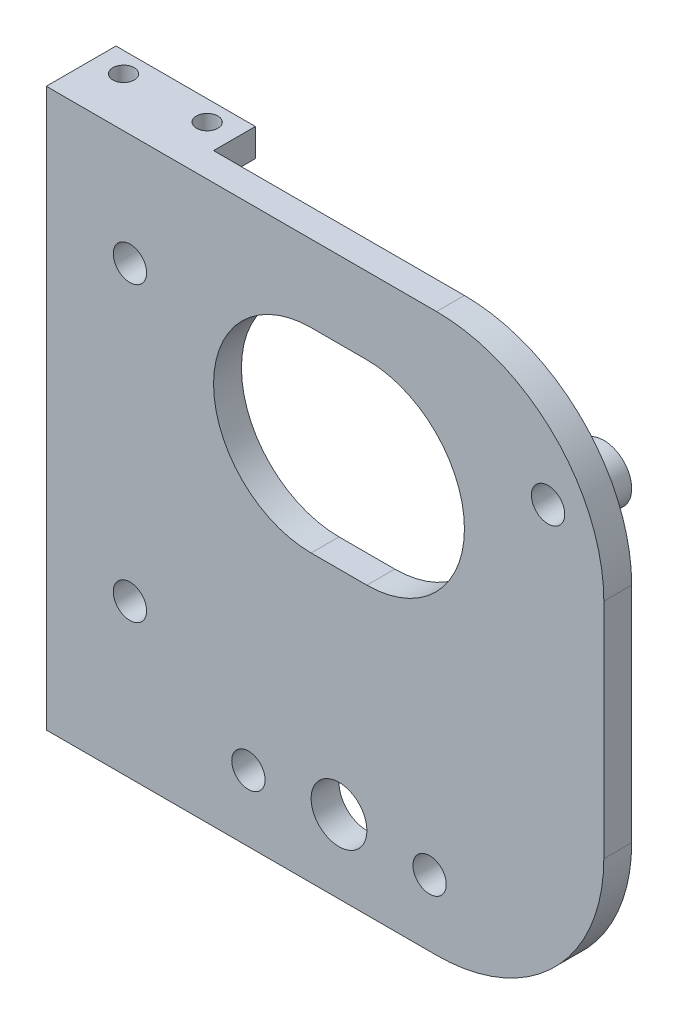
from build123d import *

# Parameters (mm, degrees)
SKETCH1_W                 = 63.5
SKETCH1_H                 = 63.5
BOSS_EXTRUDE1_DEPTH       = 3.175
BOSS_EXTRUDE2_DEPTH       = 4.7625
F_2_CLEARANCE_HOLE2_D     = 2.4384
F_2_CLEARANCE_HOLE2_DEPTH = 3.155006513
FILLET1_R                 = 19.05
SKETCH7_W                 = 15.875
SKETCH7_H                 = 3.175
BOSS_EXTRUDE3_DEPTH       = 4.7625
F_2_CLEARANCE_HOLE3_D     = 2.4384
F_2_CLEARANCE_HOLE3_DEPTH = 3.175
BOSS_EXTRUDE4_START       = -3.175
SKETCH10_R                = 3.175
BOSS_EXTRUDE4_DEPTH       = 3.175
F_6_CLEARANCE_HOLE1_D     = 3.7973
SKETCH13_R                = 3.175
CUT_EXTRUDE1_DEPTH        = 3.175


with BuildPart() as part:
    # Sketch1 → Boss-Extrude1 (new body)
    with BuildSketch(Plane.XY):
        Rectangle(SKETCH1_W, SKETCH1_H)
    extrude(amount=BOSS_EXTRUDE1_DEPTH)

    # Sketch2 → Boss-Extrude2 (add)
    with BuildSketch(Plane(origin=(0, 0, 0), x_dir=(-1, 0, 0), z_dir=(0, 0, -1))):
        Polygon((15.875, -31.75), (25.4, -31.75), (31.75, -31.75), (31.75, -28.594993487), (25.755751185, -28.594993487), (15.875, -28.594993487), align=None)
    extrude(amount=BOSS_EXTRUDE2_DEPTH)

    # #2 Clearance Hole2
    with Locations(Plane(origin=(0, -28.594993487, 0), x_dir=(1, 0, 0), z_dir=(0, 1, 0))):
        with Locations((-28.575, 2.447629477), (-19.05, 2.447629477)):
            Hole(F_2_CLEARANCE_HOLE2_D / 2, depth=F_2_CLEARANCE_HOLE2_DEPTH)

    # Fillet1
    fillet1_edges = [part.edges().sort_by_distance(p)[0] for p in [
        (31.75, -31.75, 1.5875),
        (31.75, 31.75, 1.5875),
    ]]
    fillet(fillet1_edges, radius=FILLET1_R)

    # Sketch7 → Boss-Extrude3 (add)
    with BuildSketch(Plane(origin=(0, 0, 0), x_dir=(-1, 0, 0), z_dir=(0, 0, -1))):
        with Locations((23.8125, 30.1625)):
            Rectangle(SKETCH7_W, SKETCH7_H)
    extrude(amount=BOSS_EXTRUDE3_DEPTH)

    # #2 Clearance Hole3
    with Locations(Plane(origin=(0, 31.75, 0), x_dir=(1, 0, 0), z_dir=(0, 1, 0))):
        with Locations((-28.575, 2.447629477), (-19.05, 2.447629477)):
            Hole(F_2_CLEARANCE_HOLE3_D / 2, depth=F_2_CLEARANCE_HOLE3_DEPTH)

    # Sketch10 → Boss-Extrude4 (add)
    with BuildSketch(Plane.XY.offset(3.175).offset(BOSS_EXTRUDE4_START)):
        with Locations((25.4, 19.05)):
            Circle(SKETCH10_R)
        with Locations((-22.225, 19.05)):
            Circle(SKETCH10_R)
        with Locations((-22.225, -14.2875)):
            Circle(SKETCH10_R)
        with Locations((-8.73125, -24.209375)):
            Circle(SKETCH10_R)
        with Locations((11.90625, -24.209375)):
            Circle(SKETCH10_R)
    extrude(amount=-BOSS_EXTRUDE4_DEPTH)

    # #6 Clearance Hole1 (through all)
    with Locations(Plane(origin=(0, 0, -3.175), x_dir=(-1, 0, 0), z_dir=(0, 0, -1))):
        with Locations((-25.4, 19.05), (22.225, 19.05), (22.225, -14.2875), (8.73125, -24.209375), (-11.90625, -24.209375)):
            Hole(F_6_CLEARANCE_HOLE1_D / 2)

    # Sketch13 → Cut-Extrude1 (cut)
    with BuildSketch(Plane.XY.offset(3.175)):
        with Locations((1.5875, -23.415625)):
            Circle(SKETCH13_R)
        with BuildLine():
            Line((-1.5875, 23.01875), (4.7625, 23.01875))
            ThreePointArc((4.7625, 23.01875), (15.875, 11.90625), (4.7625, 0.79375))
            Line((4.7625, 0.79375), (-1.5875, 0.79375))
            ThreePointArc((-1.5875, 0.79375), (-12.7, 11.90625), (-1.5875, 23.01875))
        make_face()
    extrude(amount=-CUT_EXTRUDE1_DEPTH, mode=Mode.SUBTRACT)


solid = part.part
